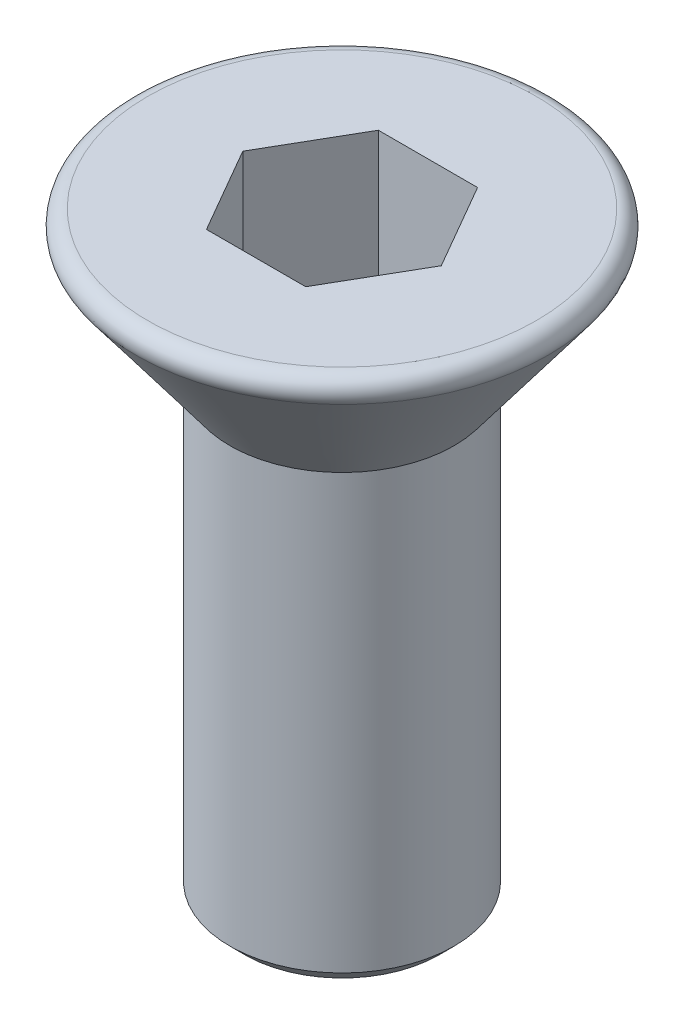
from build123d import *

# Parameters (mm, degrees)
SKETCH_2_R          = 1.5
EXTRUDE_1_DEPTH     = 6
CUT_EXTRUDE_1_DEPTH = 2
CHAMFER_1_SIZE      = 0.2
FILLET_1_R          = 0.2


with BuildPart() as part:
    # 草图1 → 旋转1 (revolve)
    with BuildSketch(Plane.XY):
        Polygon((0, 0), (0, -2), (1.5, -2), (3, 0), align=None)
    revolve(axis=Axis((0, 0, 0), (0, -1, 0)))

    # 草图2 → 凸台-拉伸1 (add)
    with BuildSketch(Plane.XZ.offset(2)):
        Circle(SKETCH_2_R)
    extrude(amount=EXTRUDE_1_DEPTH)

    # 草图3 → 切除-拉伸1 (cut)
    with BuildSketch(Plane(origin=(0, 0, 0), x_dir=(1, 0, 0), z_dir=(0, 1, 0))):
        Polygon((-1.327905619, 0), (-0.66395281, -1.15), (0.66395281, -1.15), (1.327905619, 0), (0.66395281, 1.15), (-0.66395281, 1.15), align=None)
    extrude(amount=-CUT_EXTRUDE_1_DEPTH, mode=Mode.SUBTRACT)

    # 倒角1
    chamfer_1_edges = [part.edges().sort_by_distance(p)[0] for p in [
        (-1.5, -8, 0),
    ]]
    chamfer(chamfer_1_edges, length=CHAMFER_1_SIZE)

    # 圆角1
    fillet_1_edges = [part.edges().sort_by_distance(p)[0] for p in [
        (-3, 0, 0),
    ]]
    fillet(fillet_1_edges, radius=FILLET_1_R)


solid = part.part
